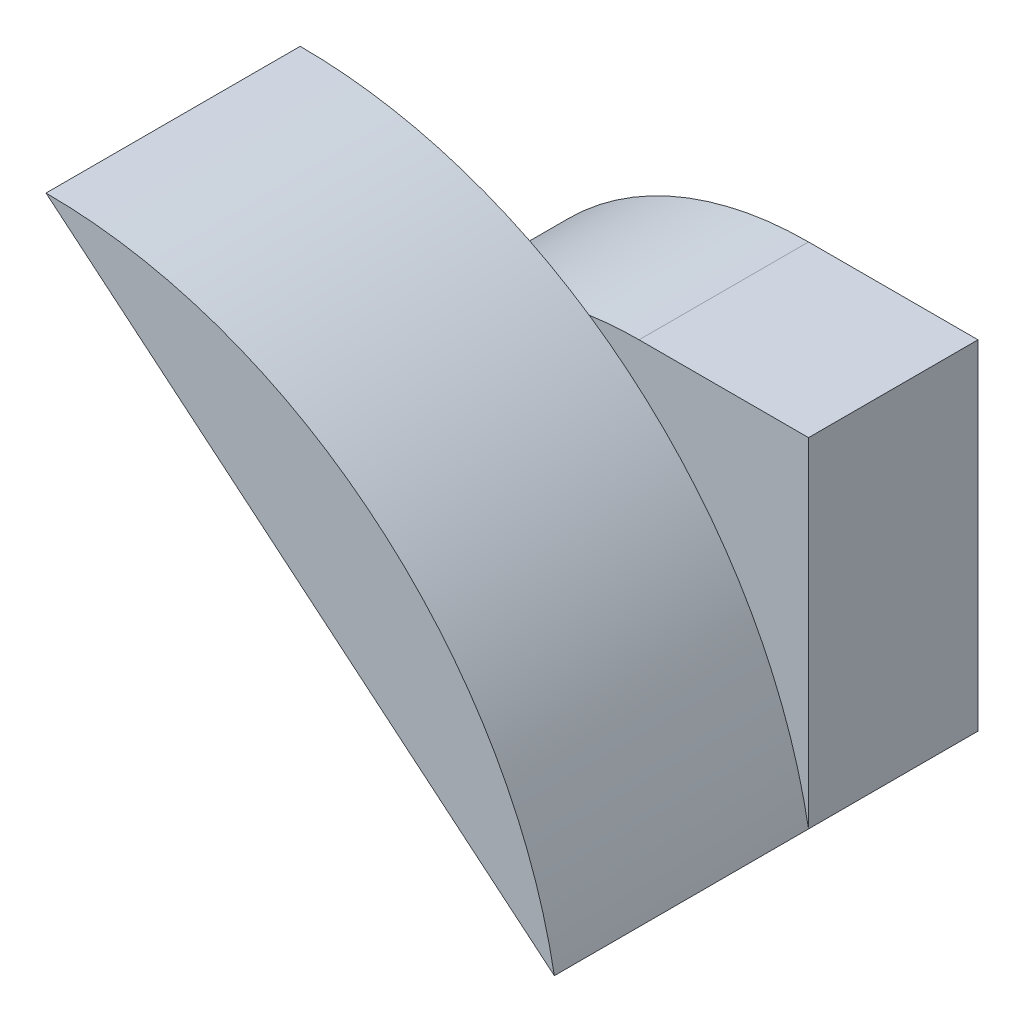
from build123d import *

# Parameters (mm, degrees)
BOSS_EXTRUDE1_DEPTH = 10
BOSS_EXTRUDE2_DEPTH = 15


with BuildPart() as part:
    # Sketch1 → Boss-Extrude1 (new body)
    with BuildSketch(Plane.XY):
        with BuildLine():
            Line((-30, 0), (0, 0))
            Line((0, 0), (0, 20))
            Line((0, 20), (-10, 20))
            ThreePointArc((-10, 20), (-24.142135624, 14.142135624), (-30, 0))
        make_face()
    extrude(amount=BOSS_EXTRUDE1_DEPTH)

    # Sketch2 → Boss-Extrude2 (add)
    with BuildSketch(Plane.XY.offset(10)):
        with BuildLine():
            Line((0, 0), (-30, 25))
            ThreePointArc((-30, 25), (-10.47437581, 17.930749028), (0, 0))
        make_face()
    extrude(amount=BOSS_EXTRUDE2_DEPTH)


solid = part.part
